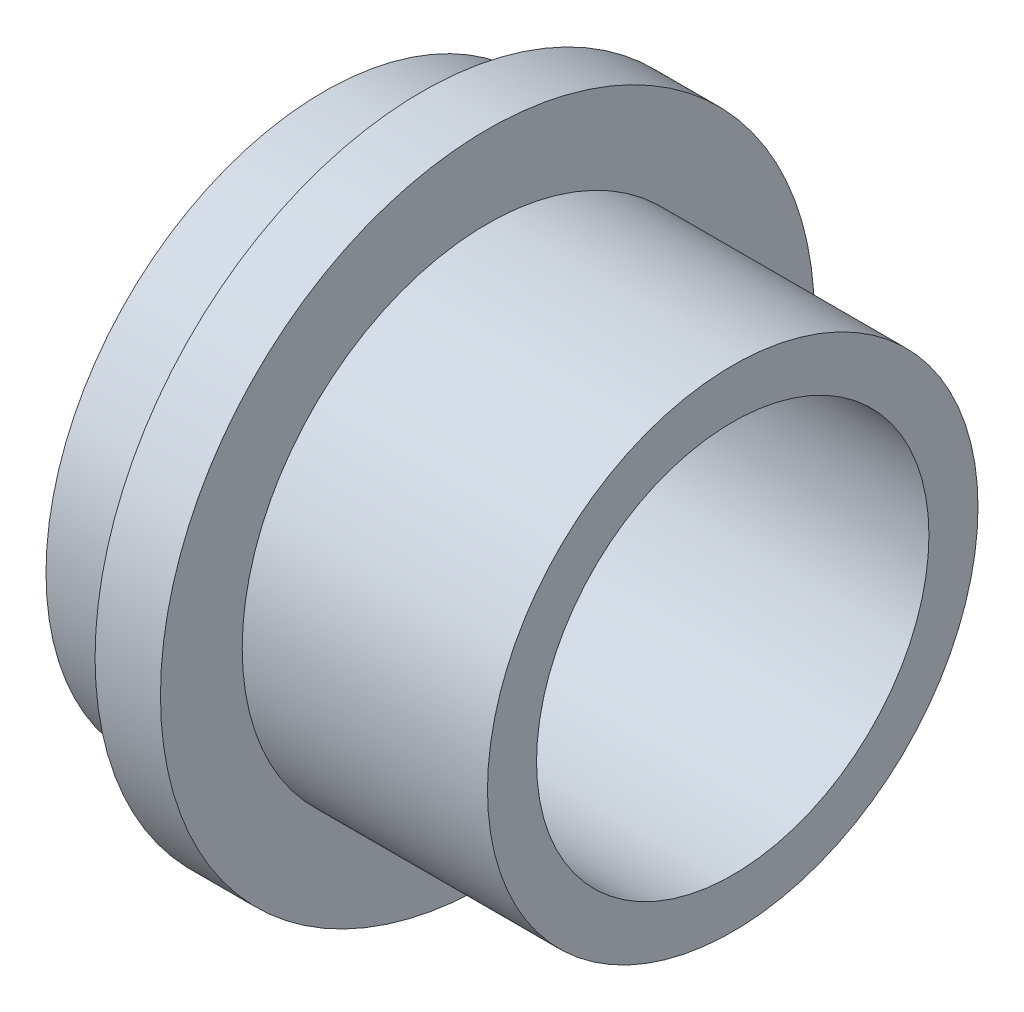
from build123d import *

# Parameters (mm, degrees)
ESQUISSE2_W             = 8
ESQUISSE2_H             = 8
ENL_V_MAT_EXTRU_1_DEPTH = 13.5
ESQUISSE3_R             = 6
ENL_V_MAT_EXTRU_2_DEPTH = 10


with BuildPart() as part:
    # Esquisse1 → Révolution1 (revolve)
    with BuildSketch(Plane.XY, mode=Mode.PRIVATE) as r_volution1_sk:
        Polygon((0, 0), (0, 8.5), (3, 8.5), (3, 9.093663992), (3, 10), (5, 10), (5, 7.5), (12.5, 7.5), (12.5, 0), align=None)
    revolve(r_volution1_sk.sketch.rotate(Axis((-59.603539616, 0, 0), (1, 0, 0)), 90), axis=Axis((-59.603539616, 0, 0), (1, 0, 0)))  # turned: the seam where the file's is

    # Esquisse2 → Enlèv. mat.-Extru.1 (cut, through all)
    with BuildSketch(Plane.ZY):
        Rectangle(ESQUISSE2_W, ESQUISSE2_H)
    extrude(amount=-ENL_V_MAT_EXTRU_1_DEPTH, mode=Mode.SUBTRACT)

    # Esquisse3 → Enlèv. mat.-Extru.2 (cut)
    with BuildSketch(Plane(origin=(12.5, 0, 0), x_dir=(0, 0, -1), z_dir=(1, 0, 0))):
        Circle(ESQUISSE3_R)
    extrude(amount=-ENL_V_MAT_EXTRU_2_DEPTH, mode=Mode.SUBTRACT)


solid = part.part
